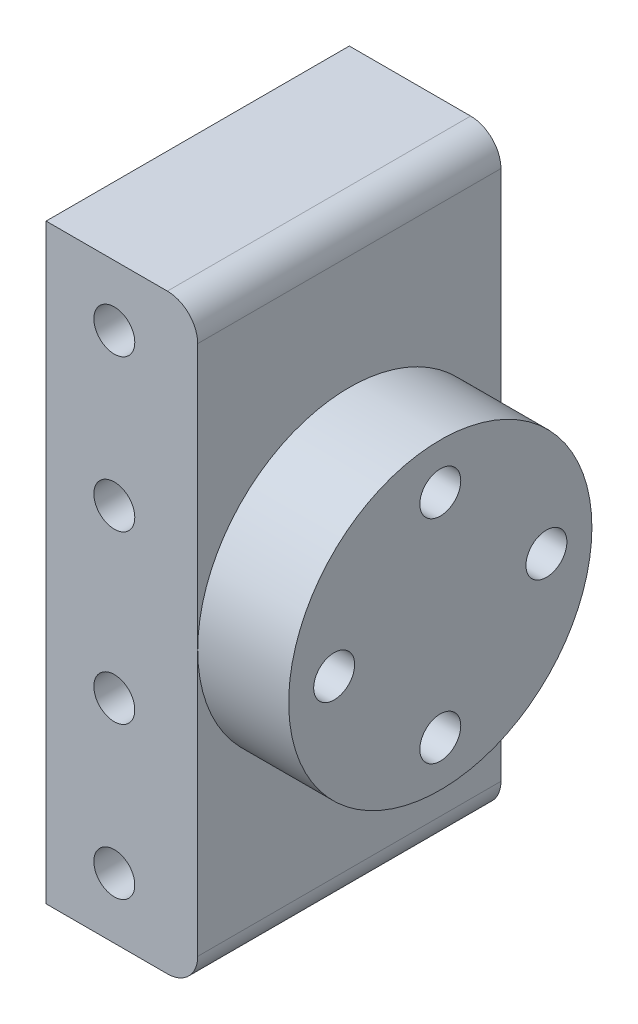
from build123d import *

# Parameters (mm, degrees)
BOSS_EXTRUDE1_DEPTH = 20
SKETCH2_R           = 1.35
CUT_EXTRUDE2_DEPTH  = 12
SKETCH3_R           = 10
BOSS_EXTRUDE2_DEPTH = 6
SKETCH4_R           = 1.35
CUT_EXTRUDE3_DEPTH  = 10


with BuildPart() as part:
    # Sketch1 → Boss-Extrude1 (new body)
    with BuildSketch(Plane.XY):
        with BuildLine():
            Line((-5, -19.5), (3, -19.5))
            ThreePointArc((3, -19.5), (4.414213562, -18.914213562), (5, -17.5))
            Line((5, -17.5), (5, 17.5))
            ThreePointArc((5, 17.5), (4.414213562, 18.914213562), (3, 19.5))
            Line((3, 19.5), (-5, 19.5))
            Line((-5, 19.5), (-5, -19.5))
        make_face()
    extrude(amount=BOSS_EXTRUDE1_DEPTH)

    # Sketch2 → Cut-Extrude2 (cut)
    with BuildSketch(Plane.XY.offset(20)):
        with Locations((-0.5, 15.5)):
            Circle(SKETCH2_R)
        with Locations((-0.5, 5.5)):
            Circle(SKETCH2_R)
        with Locations((-0.5, -15.5)):
            Circle(SKETCH2_R)
        with Locations((-0.5, -5.5)):
            Circle(SKETCH2_R)
    extrude(amount=-CUT_EXTRUDE2_DEPTH, mode=Mode.SUBTRACT)

    # Sketch3 → Boss-Extrude2 (add)
    with BuildSketch(Plane(origin=(5, 0, 0), x_dir=(0, 0, -1), z_dir=(1, 0, 0))):
        with Locations((-10, 0)):
            Circle(SKETCH3_R)
    extrude(amount=BOSS_EXTRUDE2_DEPTH)

    # Sketch4 → Cut-Extrude3 (cut)
    with BuildSketch(Plane(origin=(11, 0, 0), x_dir=(0, 0, -1), z_dir=(1, 0, 0))):
        with Locations((-17, 0)):
            Circle(SKETCH4_R)
        with Locations((-10, 7)):
            Circle(SKETCH4_R)
        with Locations((-3, 0)):
            Circle(SKETCH4_R)
        with Locations((-10, -7)):
            Circle(SKETCH4_R)
    extrude(amount=-CUT_EXTRUDE3_DEPTH, mode=Mode.SUBTRACT)


solid = part.part
